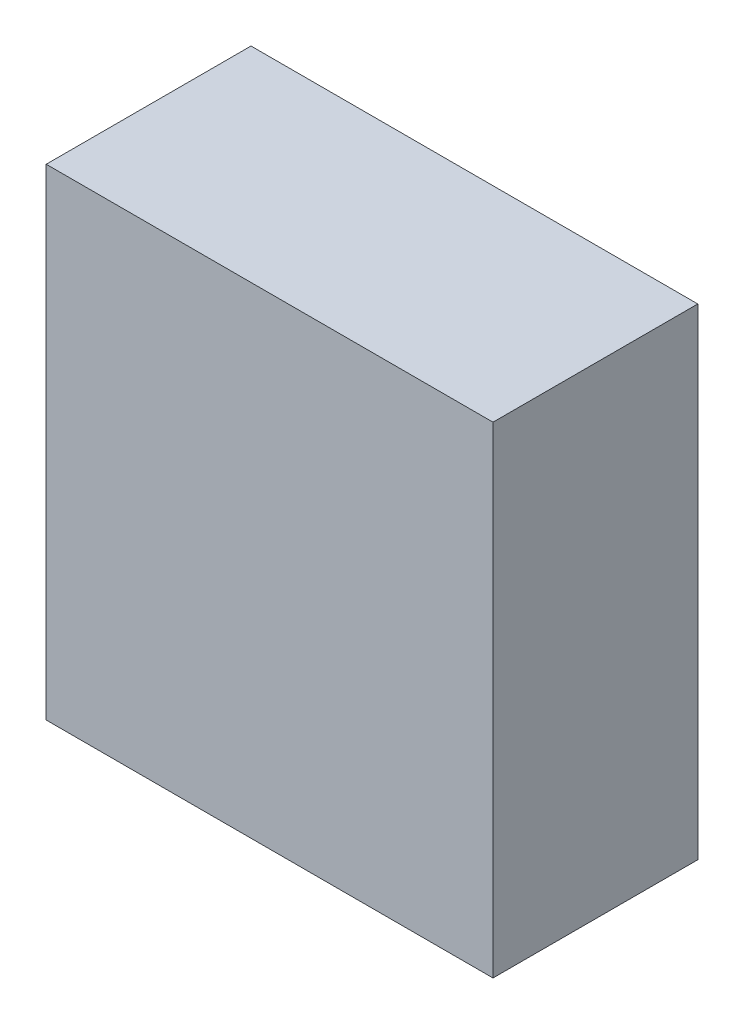
from build123d import *

# Parameters (mm, degrees)
SKETCH1_W           = 168
SKETCH1_H           = 181
BOSS_EXTRUDE1_DEPTH = 77


with BuildPart() as part:
    # Sketch1 → Boss-Extrude1 (new body)
    with BuildSketch(Plane.XY):
        with Locations((84, -90.5)):
            Rectangle(SKETCH1_W, SKETCH1_H)
    extrude(amount=BOSS_EXTRUDE1_DEPTH)


solid = part.part
